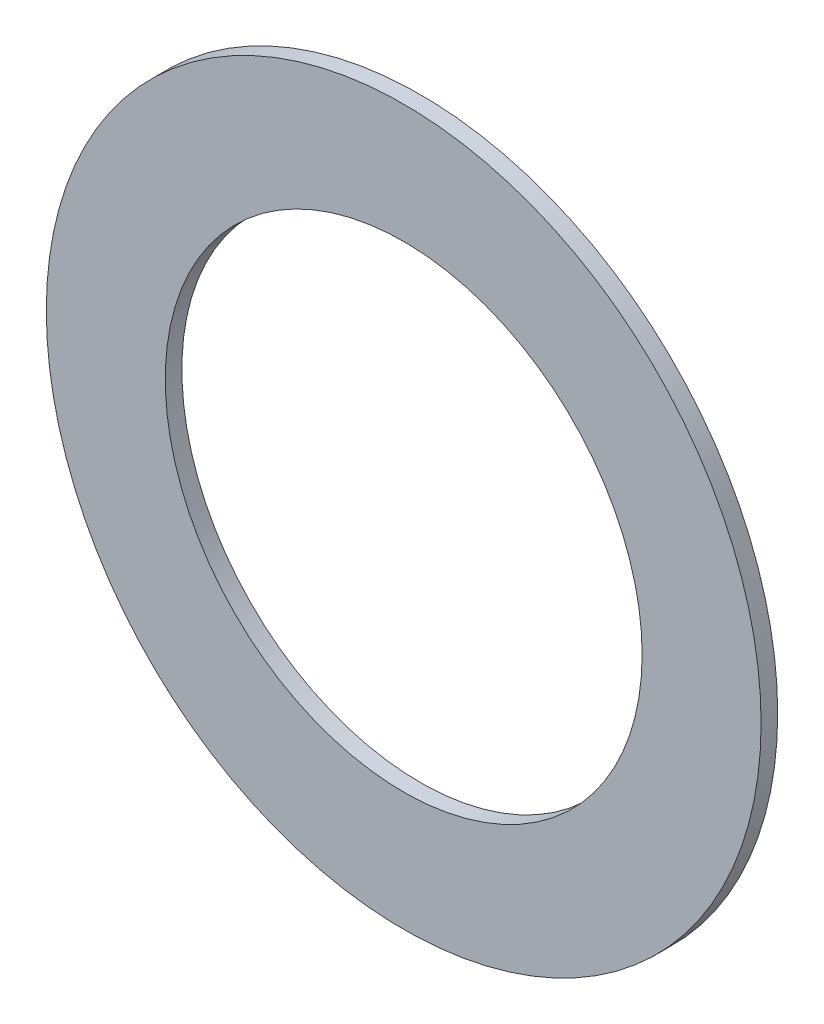
from build123d import *

# Parameters (mm, degrees)
SKETCH1_R           = 34.1884
SKETCH1_R_2         = 22.8092
BOSS_EXTRUDE1_DEPTH = 1.5875


with BuildPart() as part:
    # Sketch1 → Boss-Extrude1 (new body)
    with BuildSketch(Plane.XY):
        with Locations((164.799803954, 1350.513952992)):
            Circle(SKETCH1_R)
        with Locations((164.799803954, 1350.513952992)):
            Circle(SKETCH1_R_2, mode=Mode.SUBTRACT)
    extrude(amount=BOSS_EXTRUDE1_DEPTH)


solid = part.part
